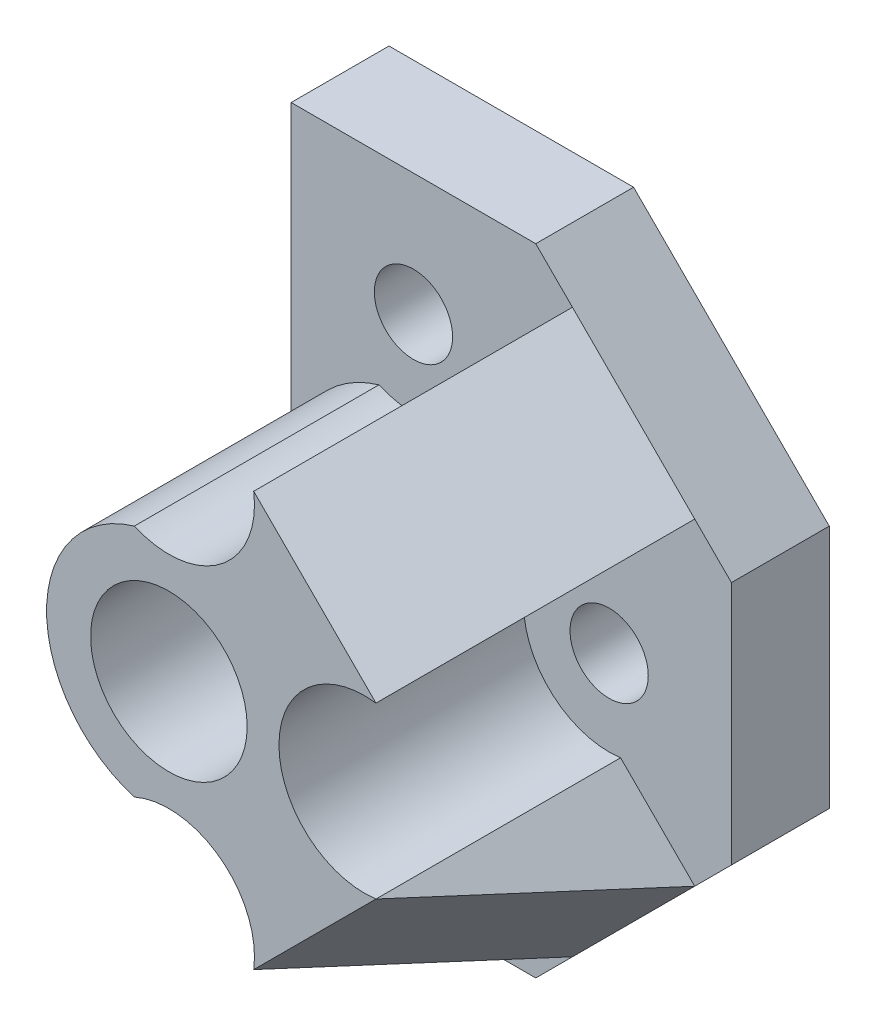
from build123d import *

# Parameters (mm, degrees)
SKETCH_1_R          = 1.6
SKETCH_1_R_2        = 3.2
EXTRUDE_1_DEPTH     = 4
SKETCH_2_R          = 3.2
EXTRUDE_2_DEPTH     = 10
CUT_EXTRUDE_1_DEPTH = 10
CUT_EXTRUDE_2_DEPTH = 10


with BuildPart() as part:
    # 草图1 → 凸台-拉伸1 (new body)
    with BuildSketch(Plane.XY):
        Polygon((0, 0), (0, 26), (10, 26), (18, 18), (18, 8), (10, 0), align=None)
        with Locations((5, 21)):
            Circle(SKETCH_1_R, mode=Mode.SUBTRACT)
        with Locations((5, 13)):
            Circle(SKETCH_1_R_2, mode=Mode.SUBTRACT)
        with Locations((5, 5)):
            Circle(SKETCH_1_R, mode=Mode.SUBTRACT)
        with Locations((13, 13)):
            Circle(SKETCH_1_R, mode=Mode.SUBTRACT)
    extrude(amount=EXTRUDE_1_DEPTH)

    # 草图2 → 凸台-拉伸2 (add)
    with BuildSketch(Plane.XY.offset(4)):
        with BuildLine():
            Line((13.468501969, 16.468501969), (16.5, 19.5))
            Line((16.5, 19.5), (11.5, 24.5))
            Line((11.5, 24.5), (8.468501969, 21.468501969))
            ThreePointArc((8.468501969, 21.468501969), (7.104490226, 18.203373302), (3.589329863, 17.796875))
            ThreePointArc((3.589329863, 17.796875), (0, 13), (3.589329863, 8.203125))
            ThreePointArc((3.589329863, 8.203125), (7.104490226, 7.796626698), (8.468501969, 4.531498031))
            Line((8.468501969, 4.531498031), (11.5, 1.5))
            Line((11.5, 1.5), (16.5, 6.5))
            Line((16.5, 6.5), (13.468501969, 9.531498031))
            ThreePointArc((13.468501969, 9.531498031), (9.5, 13), (13.468501969, 16.468501969))
        make_face()
        with Locations((5, 13)):
            Circle(SKETCH_2_R, mode=Mode.SUBTRACT)
    extrude(amount=EXTRUDE_2_DEPTH)

    # 草图3 → 切除-拉伸1 (cut)
    with BuildSketch(Plane(origin=(-1.5, 1.5, 0), x_dir=(0, 0, -1), z_dir=(0.707106781, -0.707106781, 0))):
        Polygon((-4, 25.455844123), (-14, 25.455844123), (-14, 21.168658492), align=None)
    extrude(amount=-CUT_EXTRUDE_1_DEPTH, mode=Mode.SUBTRACT)

    # 草图4 → 切除-拉伸2 (cut)
    with BuildSketch(Plane(origin=(11.5, 11.5, 0), x_dir=(0, 0, -1), z_dir=(0.707106781, 0.707106781, 0))):
        Polygon((-4, -7.071067812), (-14, -2.783882181), (-14, -7.071067812), align=None)
    extrude(amount=-CUT_EXTRUDE_2_DEPTH, mode=Mode.SUBTRACT)


solid = part.part
